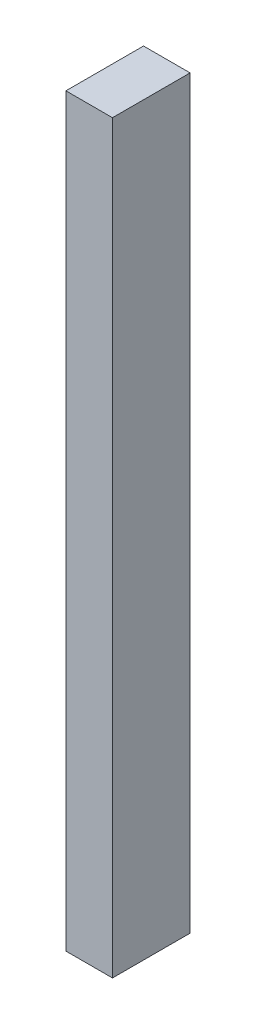
from build123d import *

# Parameters (mm, degrees)
SKETCH1_W           = 38.1
SKETCH1_H           = 63.5
BOSS_EXTRUDE1_DEPTH = 609.6


with BuildPart() as part:
    # Sketch1 → Boss-Extrude1 (new body)
    with BuildSketch(Plane(origin=(0, 0, 0), x_dir=(1, 0, 0), z_dir=(0, 1, 0))):
        Rectangle(SKETCH1_W, SKETCH1_H)
    extrude(amount=BOSS_EXTRUDE1_DEPTH)


solid = part.part
